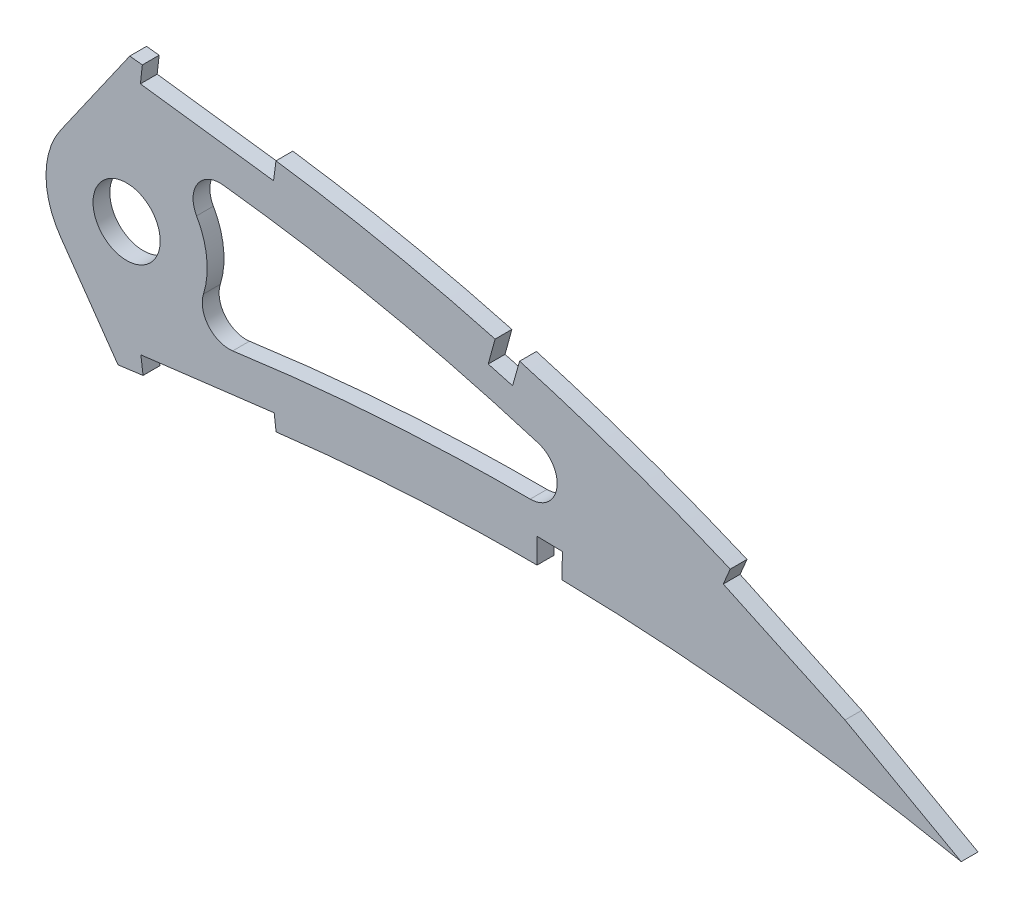
from build123d import *

# Parameters (mm, degrees)
BOSS_EXTRUDE1_DEPTH = 3.175
SKETCH3_R           = 6.35
CUT_EXTRUDE2_DEPTH  = 7.62
CUT_EXTRUDE3_DEPTH  = 4.1750001
CUT_EXTRUDE4_DEPTH  = 4.1750001
FILLET1_R           = 5.08


with BuildPart() as part:
    # Sketch1 → Boss-Extrude1 (new body)
    with BuildSketch(Plane.XY):
        with BuildLine():
            Line((468.834634376, -0.731838708), (473.237631437, -1.626460605))
            Line((473.237631437, -1.626460605), (469.420105342, 0.731838708))
            add(Edge.make_bspline(
                [(469.420105342, 0.731838708), (469.384144743, 0.75405358), (469.240441949, 0.842826831), (468.916653521, 1.041434293), (468.377478456, 1.372225024), (467.622680377, 1.832901279), (466.652845475, 2.422239826), (465.467485908, 3.136113979), (464.067341521, 3.972204372), (462.452751187, 4.926556606), (460.623880493, 5.99470234), (458.581425768, 7.172314172), (456.325564704, 8.452725095), (453.857171213, 9.830703338), (451.177092175, 11.299695359), (448.285834578, 12.853066351), (445.184433662, 14.482914856), (441.87408004, 16.182230896), (438.355377166, 17.941630348), (434.629984045, 19.753790881), (430.699141968, 21.609677497), (426.564192467, 23.499388025), (422.22751115, 25.41521975), (417.69029685, 27.345261464), (412.955135305, 29.281151436), (408.024042449, 31.211871947), (402.899937976, 33.12863011), (397.58479872, 35.019008566), (392.082597846, 36.874746386), (386.396004495, 38.68378787), (380.529085336, 40.436308543), (374.485249168, 42.120945686), (368.269534158, 43.72905958), (361.885882446, 45.248939331), (355.339704572, 46.670411418), (348.63620397, 47.984917711), (341.781002635, 49.179334611), (334.793097003, 50.252730987), (327.784920922, 51.145614984), (320.79116359, 52.021329621), (313.807821665, 52.843983365), (306.739128647, 53.631788144), (299.591885106, 54.380308437), (292.373180531, 55.087203561), (285.090322746, 55.749422771), (277.750880063, 56.365023912), (270.361954303, 56.930518839), (262.931336863, 57.445036287), (255.466373755, 57.904053071), (247.975016147, 58.307224442), (240.464868712, 58.651738691), (232.943747029, 58.935221873), (225.419637453, 59.155962801), (217.900350262, 59.311846649), (210.394026923, 59.401893322), (202.908475182, 59.423642443), (195.451832721, 59.376704816), (188.031907868, 59.259468925), (180.656846602, 59.07032975), (173.334467891, 58.808934388), (166.072689758, 58.475396129), (158.879463115, 58.066921878), (151.76259133, 57.586114694), (144.729999608, 57.030954849), (137.789414782, 56.401294687), (130.948110641, 55.699758895), (124.213703919, 54.924439317), (117.593411838, 54.077542083), (111.094475675, 53.160727588), (104.72418742, 52.173496373), (98.489371058, 51.118700137), (92.396755747, 49.997417995), (86.452787451, 48.81293722), (80.663937566, 47.565566874), (75.036333929, 46.259048591), (69.57582504, 44.895658843), (64.288280855, 43.477893405), (59.179061403, 42.009154361), (54.253333229, 40.492773824), (49.516838534, 38.930418047), (44.973157087, 37.328010693), (40.627870346, 35.686689303), (36.484306892, 34.011510412), (32.547322707, 32.304761192), (28.819858841, 30.571644792), (25.306133953, 28.814134252), (22.008652271, 27.037153572), (18.930724245, 25.243427453), (16.07531265, 23.436287722), (13.44361768, 21.620318123), (11.039267644, 19.796658613), (8.863088517, 17.969917436), (6.916457434, 16.142876281), (5.20215694, 14.316793669), (3.720125296, 12.494885385), (2.472304781, 10.678594294), (1.458911867, 8.869639065), (0.682238714, 7.069333725), (0.141515122, 5.278690749), (-0.154473369, 3.500353053), (-0.228146672, 1.732894981), (-0.07593526, 0.576768576), (0, 0)],
                knots=[0, 0, 0, 0, 0.00025409, 0.001015373, 0.002283359, 0.004056577, 0.006330982, 0.009105274, 0.012374489, 0.016134023, 0.020379661, 0.025105976, 0.030306237, 0.035972206, 0.042099522, 0.048678064, 0.055701664, 0.063160184, 0.071045824, 0.079349827, 0.08806291, 0.097175757, 0.106678111, 0.116561573, 0.126814276, 0.137428301, 0.148393618, 0.15969976, 0.171338125, 0.183297699, 0.195569604, 0.208143556, 0.221011593, 0.234161831, 0.24758745, 0.261276822, 0.27522271, 0.289414144, 0.3037712, 0.317689226, 0.331784111, 0.346039677, 0.36044387, 0.374982721, 0.389640454, 0.404403317, 0.4192566, 0.434186749, 0.449177265, 0.464214782, 0.479284009, 0.49436974, 0.509457833, 0.524532346, 0.53957932, 0.554582984, 0.569529546, 0.584403417, 0.599190992, 0.613876838, 0.628447475, 0.642888675, 0.657186054, 0.671325546, 0.685294014, 0.699078147, 0.712665095, 0.726042645, 0.739197713, 0.752117586, 0.764792042, 0.777208152, 0.789355685, 0.80122396, 0.812803686, 0.824082909, 0.835054602, 0.845709571, 0.856037853, 0.866033834, 0.875688843, 0.884997719, 0.893953426, 0.902552897, 0.910789386, 0.918660734, 0.926166253, 0.933302626, 0.94007122, 0.94647478, 0.952517526, 0.958204819, 0.963546652, 0.9685566, 0.973249913, 0.977651041, 0.981787043, 0.985694226, 0.989415109, 0.993001157, 0.996508416, 1, 1, 1, 1], degree=3))
            add(Edge.make_bspline(
                [(0, 0), (0.120545422, -0.569054782), (0.362190271, -1.709779619), (1.018707782, -3.35195076), (1.886920844, -4.930552911), (2.985051288, -6.441392915), (4.305797565, -7.884057869), (5.846242644, -9.260048331), (7.604875869, -10.568624397), (9.57939547, -11.809190578), (11.766933151, -12.983063792), (14.165030149, -14.089514173), (16.771499867, -15.128195969), (19.583502489, -16.097720727), (22.597600275, -16.999564994), (25.810927556, -17.83153108), (29.219830482, -18.594781746), (32.82103031, -19.287368785), (36.610602861, -19.909995783), (40.584611298, -20.462314276), (44.738976581, -20.94466978), (49.069622971, -21.356050059), (53.572267018, -21.697340041), (58.242420882, -21.968766107), (63.07555133, -22.171188915), (68.067028727, -22.30383895), (73.21196449, -22.368784292), (78.505709034, -22.366999873), (83.943083827, -22.298008468), (89.519444052, -22.165621357), (95.229438588, -21.969000009), (101.06791245, -21.710523747), (107.029599259, -21.392793842), (113.109152024, -21.016887343), (119.301220533, -20.584470276), (125.600428387, -20.099010447), (132.001053313, -19.561718629), (138.497513135, -18.97572672), (145.084056477, -18.343968166), (151.754992696, -17.668442476), (158.504433487, -16.952327301), (165.326367256, -16.197943271), (172.214990615, -15.40931492), (179.164010856, -14.587869186), (186.167551809, -13.738296088), (193.219024932, -12.862218898), (200.312533746, -11.963011893), (207.44169833, -11.044909074), (214.599844565, -10.107805674), (221.780951957, -9.158378258), (228.978095261, -8.195844739), (236.185009877, -7.225155571), (243.39502444, -6.249327898), (250.601116302, -5.268662037), (257.796951099, -4.287222096), (264.975853334, -3.307702419), (272.13079123, -2.33019238), (279.255291474, -1.35955068), (286.342179994, -0.395658656), (293.38492181, 0.559529456), (300.37676799, 1.503162571), (307.311122172, 2.434049592), (314.180831105, 3.351601668), (320.978983246, 4.256163344), (327.596964914, 5.120278953), (334.01748331, 5.989962795), (340.262174398, 6.702910859), (346.429111082, 7.311437642), (352.524699362, 7.810345682), (358.541619746, 8.206812681), (364.472978221, 8.503671562), (370.311705825, 8.705066897), (376.050427401, 8.816973355), (381.681975143, 8.842230751), (387.198662126, 8.788893941), (392.593313409, 8.66126226), (397.85839984, 8.46506453), (402.98657623, 8.20692007), (407.970558399, 7.89386613), (412.802863889, 7.530520429), (417.476759125, 7.125365523), (421.985033014, 6.684332445), (426.320762922, 6.212460013), (430.477622429, 5.719635759), (434.44895803, 5.209104646), (438.228796305, 4.68925635), (441.811052689, 4.165359017), (445.190053843, 3.644101417), (448.360490845, 3.130455994), (451.317242447, 2.631240452), (454.055677032, 2.151118888), (456.571042556, 1.694780117), (458.859849552, 1.267981745), (460.917577703, 0.872844052), (462.741474942, 0.515878932), (464.328149845, 0.198661447), (465.675276413, -0.074339095), (466.780502068, -0.302045374), (467.642148233, -0.480719316), (468.258513042, -0.610646491), (468.628929808, -0.68795975), (468.793510743, -0.723066602), (468.834634376, -0.731838708)],
                knots=[0, 0, 0, 0, 0.003638255, 0.007293231, 0.011028136, 0.014901081, 0.018963272, 0.023258475, 0.027820626, 0.032679082, 0.03785316, 0.043361875, 0.049214679, 0.055422346, 0.061988786, 0.068918036, 0.076211157, 0.083868392, 0.091887411, 0.100265912, 0.108999867, 0.118084529, 0.127514843, 0.13728527, 0.147387917, 0.157816481, 0.168563473, 0.179619128, 0.190977373, 0.202626974, 0.214560478, 0.226767249, 0.239236417, 0.251959004, 0.264923894, 0.278119703, 0.291536035, 0.30516028, 0.318980685, 0.332985499, 0.34716279, 0.361498603, 0.375980747, 0.390597192, 0.405332593, 0.420174823, 0.435109533, 0.450124276, 0.465203068, 0.480333154, 0.495500583, 0.510689775, 0.525887334, 0.541078314, 0.556247233, 0.571381785, 0.58646604, 0.601484516, 0.616424329, 0.631269423, 0.646006524, 0.660620684, 0.675098188, 0.689422858, 0.703581824, 0.716907564, 0.730009274, 0.742952128, 0.755725558, 0.768319952, 0.780724337, 0.792926528, 0.804916041, 0.816679084, 0.828203524, 0.8394749, 0.850481359, 0.861207697, 0.871639326, 0.881763414, 0.891563605, 0.901027364, 0.910138977, 0.918883976, 0.927249278, 0.935221104, 0.942784738, 0.949928188, 0.956638464, 0.962904204, 0.968712288, 0.974054485, 0.978918432, 0.983297218, 0.987180246, 0.990560674, 0.993433357, 0.995790626, 0.997629587, 0.998945816, 0.999736592, 1, 1, 1, 1], degree=3))
        make_face()
    extrude(amount=BOSS_EXTRUDE1_DEPTH)

    # Sketch3 → Cut-Extrude2 (cut)
    with BuildSketch(Plane(origin=(0, 0, 0), x_dir=(-1, 0, 0), z_dir=(0, 0, -1))):
        with Locations((-305.693087566, 26.255421435)):
            Circle(SKETCH3_R)
    extrude(amount=-CUT_EXTRUDE2_DEPTH, mode=Mode.SUBTRACT)

    # Sketch5 → Cut-Extrude3 (cut, through all)
    with BuildSketch(Plane.XY.offset(3.175)):
        with BuildLine():
            Line((297.512883475, 11.367834437), (293.209210411, 17.514116545))
            ThreePointArc((293.209210411, 17.514116545), (290.453087566, 26.255421435), (293.209210411, 34.996726325))
            Line((293.209210411, 34.996726325), (299.622888229, 44.156407516))
            Line((299.622888229, 44.156407516), (306.28625024, 53.672674691))
            add(Edge.make_bspline(
                [(306.28625024, 53.672674691), (304.062685855, 53.912052152), (299.432854271, 54.395881608), (292.373180531, 55.087203561), (285.090322746, 55.749422771), (277.750880063, 56.365023912), (270.361954303, 56.930518839), (262.931336863, 57.445036287), (255.466373755, 57.904053071), (247.975016147, 58.307224442), (240.464868712, 58.651738691), (232.943747029, 58.935221873), (225.419637453, 59.155962801), (217.900350262, 59.311846649), (210.394026923, 59.401893322), (202.908475182, 59.423642443), (195.451832721, 59.376704816), (188.031907868, 59.259468925), (180.656846602, 59.07032975), (173.334467891, 58.808934388), (166.072689758, 58.475396129), (159.219577295, 58.086235587), (154.78924534, 57.790330672), (152.756670288, 57.644702109)],
                knots=[0.347000218, 0.347000218, 0.347000218, 0.347000218, 0.36044387, 0.374982721, 0.389640454, 0.404403317, 0.4192566, 0.434186749, 0.449177265, 0.464214782, 0.479284009, 0.49436974, 0.509457833, 0.524532346, 0.53957932, 0.554582984, 0.569529546, 0.584403417, 0.599190992, 0.613876838, 0.628447475, 0.642888675, 0.655138283, 0.655138283, 0.655138283, 0.655138283], degree=3))
            add(Edge.make_bspline(
                [(152.756670288, 57.644702109), (152.416884114, 57.620357339), (149.731090186, 57.425745956), (144.729999608, 57.030954849), (137.789414782, 56.401294687), (130.948110641, 55.699758895), (124.213703919, 54.924439317), (117.593411838, 54.077542083), (111.094475675, 53.160727588), (104.72418742, 52.173496373), (98.489371058, 51.118700137), (92.396755747, 49.997417995), (86.452787451, 48.81293722), (80.663937566, 47.565566874), (75.036333929, 46.259048591), (69.57582504, 44.895658843), (64.288280855, 43.477893405), (59.179061403, 42.009154361), (54.253333229, 40.492773824), (49.516838534, 38.930418047), (44.973157087, 37.328010693), (40.627870346, 35.686689303), (36.484306892, 34.011510412), (32.547322707, 32.304761192), (28.819858841, 30.571644792), (25.306133953, 28.814134252), (22.008652271, 27.037153572), (18.930724245, 25.243427453), (16.07531265, 23.436287722), (13.44361768, 21.620318123), (11.039267644, 19.796658613), (8.863088517, 17.969917436), (6.916457434, 16.142876281), (5.20215694, 14.316793669), (3.720125296, 12.494885385), (2.472304781, 10.678594294), (1.458911867, 8.869639065), (0.682238714, 7.069333725), (0.141515122, 5.278690749), (-0.154473369, 3.500353053), (-0.228146672, 1.732894981), (-0.07593526, 0.576768576), (0, 0)],
                knots=[0.655138283, 0.655138283, 0.655138283, 0.655138283, 0.657186054, 0.671325546, 0.685294014, 0.699078147, 0.712665095, 0.726042645, 0.739197713, 0.752117586, 0.764792042, 0.777208152, 0.789355685, 0.80122396, 0.812803686, 0.824082909, 0.835054602, 0.845709571, 0.856037853, 0.866033834, 0.875688843, 0.884997719, 0.893953426, 0.902552897, 0.910789386, 0.918660734, 0.926166253, 0.933302626, 0.94007122, 0.94647478, 0.952517526, 0.958204819, 0.963546652, 0.9685566, 0.973249913, 0.977651041, 0.981787043, 0.985694226, 0.989415109, 0.993001157, 0.996508416, 1, 1, 1, 1], degree=3))
            add(Edge.make_bspline(
                [(0, 0), (0.120545422, -0.569054782), (0.362190271, -1.709779619), (1.018707782, -3.35195076), (1.886920844, -4.930552911), (2.985051288, -6.441392915), (4.305797565, -7.884057869), (5.846242644, -9.260048331), (7.604875869, -10.568624397), (9.57939547, -11.809190578), (11.766933151, -12.983063792), (14.165030149, -14.089514173), (16.771499867, -15.128195969), (19.583502489, -16.097720727), (22.597600275, -16.999564994), (25.810927556, -17.83153108), (29.219830482, -18.594781746), (32.82103031, -19.287368785), (36.610602861, -19.909995783), (40.584611298, -20.462314276), (44.738976581, -20.94466978), (49.069622971, -21.356050059), (53.572267018, -21.697340041), (58.242420882, -21.968766107), (63.07555133, -22.171188915), (68.067028727, -22.30383895), (73.21196449, -22.368784292), (78.505709034, -22.366999873), (83.943083827, -22.298008468), (89.519444052, -22.165621357), (95.229438588, -21.969000009), (101.06791245, -21.710523747), (107.029599259, -21.392793842), (113.109152024, -21.016887343), (119.301220533, -20.584470276), (125.600428387, -20.099010447), (132.001053313, -19.561718629), (138.497513135, -18.97572672), (145.084056477, -18.343968166), (151.754992696, -17.668442476), (158.504433487, -16.952327301), (165.326367256, -16.197943271), (172.214990615, -15.40931492), (178.413668021, -14.676567434), (182.315287371, -14.20522514), (183.900274287, -14.012143441)],
                knots=[0, 0, 0, 0, 0.003638255, 0.007293231, 0.011028136, 0.014901081, 0.018963272, 0.023258475, 0.027820626, 0.032679082, 0.03785316, 0.043361875, 0.049214679, 0.055422346, 0.061988786, 0.068918036, 0.076211157, 0.083868392, 0.091887411, 0.100265912, 0.108999867, 0.118084529, 0.127514843, 0.13728527, 0.147387917, 0.157816481, 0.168563473, 0.179619128, 0.190977373, 0.202626974, 0.214560478, 0.226767249, 0.239236417, 0.251959004, 0.264923894, 0.278119703, 0.291536035, 0.30516028, 0.318980685, 0.332985499, 0.34716279, 0.361498603, 0.375980747, 0.390597192, 0.400599477, 0.400599477, 0.400599477, 0.400599477], degree=3))
            Line((183.900274287, -14.012143441), (182.671674675, -3.926701309))
            add(Edge.make_bspline(
                [(182.671674675, -3.926701309), (194.509091827, -2.484677654), (218.145124651, 0.570902493), (247.751689591, 4.59382325), (271.453325847, 7.832408284), (286.063540768, 9.821970798), (294.75504791, 10.996225318), (297.512883475, 11.367834437)],
                knots=[0.400599477, 0.400599477, 0.400599477, 0.400599477, 0.475524542, 0.550449608, 0.587912141, 0.625374673, 0.642787324, 0.642787324, 0.642787324, 0.642787324], degree=3))
        make_face()
        with BuildLine():
            Line((304.072913741, 1.999140288), (297.512883475, 11.367834437))
            add(Edge.make_bspline(
                [(182.671674675, -3.926701309), (194.509091827, -2.484677654), (218.145124651, 0.570902493), (247.751689591, 4.59382325), (271.453325847, 7.832408284), (286.063540768, 9.821970798), (294.75504791, 10.996225318), (297.512883475, 11.367834437)],
                knots=[0.400599477, 0.400599477, 0.400599477, 0.400599477, 0.475524542, 0.550449608, 0.587912141, 0.625374673, 0.642787324, 0.642787324, 0.642787324, 0.642787324], degree=3))
            Line((182.671674675, -3.926701309), (183.900274287, -14.012143441))
            add(Edge.make_bspline(
                [(183.900274287, -14.012143441), (184.650295648, -13.920776504), (187.752075182, -13.541434417), (193.219024932, -12.862218898), (200.312533746, -11.963011893), (207.44169833, -11.044909074), (214.599844565, -10.107805674), (221.780951957, -9.158378258), (228.978095261, -8.195844739), (236.185009877, -7.225155571), (243.39502444, -6.249327898), (250.601116302, -5.268662037), (257.796951099, -4.287222096), (264.975853334, -3.307702419), (272.13079123, -2.33019238), (279.255291474, -1.35955068), (286.342179994, -0.395658656), (293.38492181, 0.559529456), (299.290252779, 1.356524372), (302.847355272, 1.834638254), (304.072913741, 1.999140288)],
                knots=[0.400599477, 0.400599477, 0.400599477, 0.400599477, 0.405332593, 0.420174823, 0.435109533, 0.450124276, 0.465203068, 0.480333154, 0.495500583, 0.510689775, 0.525887334, 0.541078314, 0.556247233, 0.571381785, 0.58646604, 0.601484516, 0.616424329, 0.631269423, 0.646006524, 0.653752682, 0.653752682, 0.653752682, 0.653752682], degree=3))
        make_face()
        with BuildLine():
            ThreePointArc((323.963245575, 41.38375935), (319.105220017, 39.160601573), (318.92248425, 33.821177403))
            ThreePointArc((318.92248425, 33.821177403), (320.421862217, 30.169600438), (320.933087566, 26.255421435))
            ThreePointArc((320.933087566, 26.255421435), (319.141171906, 19.085579904), (314.186810981, 13.601794976))
            add(Edge.make_bspline(
                [(314.186810981, 13.601794976), (314.770369848, 13.679448559), (316.839424195, 13.954520017), (320.400865114, 14.426308147), (324.846022745, 15.007024156), (329.250239262, 15.599262537), (333.841569886, 16.194898181), (338.429624656, 16.716888646), (347.573325078, 17.657008471), (361.374068863, 18.662672255), (379.786507532, 19.131635965), (397.590418024, 18.759722594), (409.224653606, 18.017132069), (414.729715702, 17.55731843)],
                knots=[0.677887055, 0.677887055, 0.677887055, 0.677887055, 0.681568472, 0.690934105, 0.700299739, 0.709665372, 0.719031005, 0.728396638, 0.737762271, 0.775224804, 0.812687337, 0.850149869, 0.883923306, 0.883923306, 0.883923306, 0.883923306], degree=3))
            add(Edge.make_bspline(
                [(414.729715702, 17.55731843), (413.495056563, 18.076609121), (406.144215059, 21.11795465), (392.493349368, 26.215886187), (373.537808804, 32.037686314), (357.474318794, 35.923573168), (346.138104248, 38.119647891), (339.615899628, 39.226410516), (334.729973243, 39.983396346), (329.989581028, 40.625614959), (326.342829232, 41.085317779), (324.383215707, 41.331189805), (323.963245575, 41.38375935)],
                knots=[0.114549081, 0.114549081, 0.114549081, 0.114549081, 0.122838428, 0.163784571, 0.204730714, 0.245676856, 0.266149928, 0.276386463, 0.286622999, 0.296859535, 0.306234702, 0.308793836, 0.308793836, 0.308793836, 0.308793836], degree=3))
        make_face()
    extrude(amount=-CUT_EXTRUDE3_DEPTH, mode=Mode.SUBTRACT)

    # Sketch6 → Cut-Extrude4 (cut, through all)
    with BuildSketch(Plane.XY.offset(3.175)):
        with BuildLine():
            add(Edge.make_bspline(
                [(333.929911323, 50.341851873), (331.859314578, 50.626471459), (327.488961608, 51.182673162), (320.79116359, 52.021329621), (314.442152858, 52.769257691), (310.390101293, 53.224342073), (308.667703913, 53.413625761)],
                knots=[0.291207141, 0.291207141, 0.291207141, 0.291207141, 0.3037712, 0.317689226, 0.331784111, 0.342200224, 0.342200224, 0.342200224, 0.342200224], degree=3))
            Line((333.929911323, 50.341851873), (334.512065277, 54.823626972))
            Line((334.512065277, 54.823626972), (309.146518106, 57.674243029))
            Line((309.146518106, 57.674243029), (308.667703913, 53.413625761))
        make_face()
        Polygon((308.652395584, 53.277408137), (308.297850756, 50.122573044), (333.476163247, 46.848623298), (333.885132121, 49.99711435), align=None)
        with BuildLine():
            Line((377.256283552, 48.81691022), (375.355182384, 41.865517827))
            add(Edge.make_bspline(
                [(379.995119199, 40.570141398), (378.451581941, 41.012961679), (376.904875173, 41.44473681), (375.355182384, 41.865517827)],
                knots=[0.196772604, 0.196772604, 0.196772604, 0.196772604, 0.206425369, 0.206425369, 0.206425369, 0.206425369], degree=3))
            Line((379.995119199, 40.570141398), (381.952411943, 47.532589804))
            Line((381.952411943, 47.532589804), (377.256283552, 48.81691022))
        make_face()
        Polygon((375.317230972, 41.726748172), (374.060981287, 37.133260641), (378.654468816, 35.877010948), (379.953838632, 40.423298869), align=None)
        with BuildLine():
            Line((422.639110826, 33.097771033), (419.814536432, 26.438469199))
            add(Edge.make_bspline(
                [(469.420105342, 0.731838708), (469.384144743, 0.75405358), (469.240441949, 0.842826831), (468.916653521, 1.041434293), (468.377478456, 1.372225024), (467.622680377, 1.832901279), (466.652845475, 2.422239826), (465.467485908, 3.136113979), (464.067341521, 3.972204372), (462.452751187, 4.926556606), (460.623880493, 5.99470234), (458.581425768, 7.172314172), (456.325564704, 8.452725095), (453.857171213, 9.830703338), (451.177092175, 11.299695359), (448.285834578, 12.853066351), (445.184433662, 14.482914856), (441.87408004, 16.182230896), (438.355377166, 17.941630348), (434.629984045, 19.753790881), (430.699141968, 21.609677497), (426.564192467, 23.499388025), (422.913014033, 25.112382609), (420.638113453, 26.088706889), (419.814536432, 26.438469199)],
                knots=[0, 0, 0, 0, 0.00025409, 0.001015373, 0.002283359, 0.004056577, 0.006330982, 0.009105274, 0.012374489, 0.016134023, 0.020379661, 0.025105976, 0.030306237, 0.035972206, 0.042099522, 0.048678064, 0.055701664, 0.063160184, 0.071045824, 0.079349827, 0.08806291, 0.097175757, 0.106678111, 0.112056765, 0.112056765, 0.112056765, 0.112056765], degree=3))
            Line((469.420105342, 0.731838708), (473.237631437, -1.626460605))
            Line((473.237631437, -1.626460605), (468.834634376, -0.731838708))
            add(Edge.make_bspline(
                [(463.749174115, 0.314183331), (463.968637418, 0.270270157), (464.637675863, 0.135934772), (465.675276413, -0.074339095), (466.780502068, -0.302045374), (467.642148233, -0.480719316), (468.258513042, -0.610646491), (468.628929808, -0.68795975), (468.793510743, -0.723066602), (468.834634376, -0.731838708)],
                knots=[0.989158632, 0.989158632, 0.989158632, 0.989158632, 0.990560674, 0.993433357, 0.995790626, 0.997629587, 0.998945816, 0.999736592, 1, 1, 1, 1], degree=3))
            Line((463.749174115, 0.314183331), (463.708217496, 0.240451635))
            Line((463.708217496, 0.240451635), (477.098083011, -7.197375657))
            Line((477.098083011, -7.197375657), (481.361821085, 0.478371192))
            Line((481.361821085, 0.478371192), (422.639110826, 33.097771033))
        make_face()
        with BuildLine():
            add(Edge.make_bspline(
                [(383.284143211, 8.821702739), (384.602443262, 8.812950046), (386.170805311, 8.794643543), (387.739009395, 8.766883068), (387.989086643, 8.762215879)],
                knots=[0.819945141, 0.819945141, 0.819945141, 0.819945141, 0.828203524, 0.829770352, 0.829770352, 0.829770352, 0.829770352], degree=3))
            Line((387.989086643, 8.762215879), (388.085526515, 13.444014284))
            Line((388.085526515, 13.444014284), (383.32453269, 13.542120476))
            Line((383.32453269, 13.542120476), (383.28414321, 8.821702739))
        make_face()
        Polygon((383.231357966, 2.65256153), (387.863234516, 2.65256153), (387.98804622, 8.711707232), (383.283788284, 8.780221608), align=None)
        with BuildLine():
            Line((308.38825603, 5.800209772), (308.801977154, 2.652337229))
            Line((308.801977154, 2.652337229), (310.701505473, 2.886714965))
            add(Edge.make_bspline(
                [(310.701505473, 2.886714965), (311.869345474, 3.042728563), (315.303820941, 3.501026622), (320.978983246, 4.256163344), (327.564082502, 5.115985468), (331.879148983, 5.700318423), (333.95703077, 5.960133358)],
                knots=[0.667717454, 0.667717454, 0.667717454, 0.667717454, 0.675098188, 0.689422858, 0.703581824, 0.716699828, 0.716699828, 0.716699828, 0.716699828], degree=3))
            Line((333.95703077, 5.960133358), (333.591696942, 8.909442836))
            Line((333.591696942, 8.909442836), (308.38825603, 5.800209772))
        make_face()
        with BuildLine():
            add(Edge.make_bspline(
                [(308.804349352, 2.633111611), (309.436727547, 2.717699531), (310.069113071, 2.802232662), (310.701505473, 2.886714965)],
                knots=[0.663720743, 0.663720743, 0.663720743, 0.663720743, 0.667717454, 0.667717454, 0.667717454, 0.667717454], degree=3))
            Line((308.804349352, 2.633111611), (309.311930258, -1.480608059))
            Line((309.311930258, -1.480608059), (334.491870837, 1.626277701))
            Line((334.491870837, 1.626277701), (333.981917733, 5.759222988))
            Line((333.981917733, 5.759222988), (310.701505473, 2.886714965))
        make_face()
        with BuildLine():
            Line((308.652395584, 53.277408137), (333.885132121, 49.99711435))
            Line((333.885132121, 49.99711435), (333.929911323, 50.341851873))
            add(Edge.make_bspline(
                [(333.929911323, 50.341851873), (331.859314578, 50.626471459), (327.488961608, 51.182673162), (320.79116359, 52.021329621), (314.442152858, 52.769257691), (310.390101293, 53.224342073), (308.667703913, 53.413625761)],
                knots=[0.291207141, 0.291207141, 0.291207141, 0.291207141, 0.3037712, 0.317689226, 0.331784111, 0.342200224, 0.342200224, 0.342200224, 0.342200224], degree=3))
            Line((308.667703913, 53.413625761), (308.652395584, 53.277408137))
        make_face()
        with BuildLine():
            add(Edge.make_bspline(
                [(379.995119199, 40.570141398), (378.451581941, 41.012961679), (376.904875173, 41.44473681), (375.355182384, 41.865517827)],
                knots=[0.196772604, 0.196772604, 0.196772604, 0.196772604, 0.206425369, 0.206425369, 0.206425369, 0.206425369], degree=3))
            Line((375.355182384, 41.865517827), (375.317230972, 41.726748172))
            Line((375.317230972, 41.726748172), (379.953838632, 40.423298869))
            Line((379.953838632, 40.423298869), (379.995119199, 40.570141398))
        make_face()
        with BuildLine():
            add(Edge.make_bspline(
                [(469.420105342, 0.731838708), (469.384144743, 0.75405358), (469.240441949, 0.842826831), (468.916653521, 1.041434293), (468.377478456, 1.372225024), (467.622680377, 1.832901279), (466.652845475, 2.422239826), (465.467485908, 3.136113979), (464.067341521, 3.972204372), (462.452751187, 4.926556606), (460.623880493, 5.99470234), (458.581425768, 7.172314172), (456.325564704, 8.452725095), (453.857171213, 9.830703338), (451.177092175, 11.299695359), (448.285834578, 12.853066351), (445.184433662, 14.482914856), (441.87408004, 16.182230896), (438.355377166, 17.941630348), (434.629984045, 19.753790881), (430.699141968, 21.609677497), (426.564192467, 23.499388025), (422.913014033, 25.112382609), (420.638113453, 26.088706889), (419.814536432, 26.438469199)],
                knots=[0, 0, 0, 0, 0.00025409, 0.001015373, 0.002283359, 0.004056577, 0.006330982, 0.009105274, 0.012374489, 0.016134023, 0.020379661, 0.025105976, 0.030306237, 0.035972206, 0.042099522, 0.048678064, 0.055701664, 0.063160184, 0.071045824, 0.079349827, 0.08806291, 0.097175757, 0.106678111, 0.112056765, 0.112056765, 0.112056765, 0.112056765], degree=3))
            Line((419.814536432, 26.438469199), (419.733830693, 26.248194912))
            Line((419.733830693, 26.248194912), (418.494223412, 23.325659377))
            Line((418.494223412, 23.325659377), (441.504279945, 12.574335985))
            Line((441.504279945, 12.574335985), (463.477912059, 0.368382126))
            add(Edge.make_bspline(
                [(463.477912059, 0.368382126), (463.568337872, 0.350341588), (463.65875848, 0.33227491), (463.749174115, 0.314183331)],
                knots=[0.988581011, 0.988581011, 0.988581011, 0.988581011, 0.989158632, 0.989158632, 0.989158632, 0.989158632], degree=3))
            add(Edge.make_bspline(
                [(463.749174115, 0.314183331), (463.968637418, 0.270270157), (464.637675863, 0.135934772), (465.675276413, -0.074339095), (466.780502068, -0.302045374), (467.642148233, -0.480719316), (468.258513042, -0.610646491), (468.628929808, -0.68795975), (468.793510743, -0.723066602), (468.834634376, -0.731838708)],
                knots=[0.989158632, 0.989158632, 0.989158632, 0.989158632, 0.990560674, 0.993433357, 0.995790626, 0.997629587, 0.998945816, 0.999736592, 1, 1, 1, 1], degree=3))
            Line((468.834634376, -0.731838708), (473.237631437, -1.626460605))
            Line((473.237631437, -1.626460605), (469.420105342, 0.731838708))
        make_face()
        with BuildLine():
            add(Edge.make_bspline(
                [(310.701505473, 2.886714965), (311.869345474, 3.042728563), (315.303820941, 3.501026622), (320.978983246, 4.256163344), (327.564082502, 5.115985468), (331.879148983, 5.700318423), (333.95703077, 5.960133358)],
                knots=[0.667717454, 0.667717454, 0.667717454, 0.667717454, 0.675098188, 0.689422858, 0.703581824, 0.716699828, 0.716699828, 0.716699828, 0.716699828], degree=3))
            Line((310.701505473, 2.886714965), (333.981917733, 5.759222988))
            Line((333.981917733, 5.759222988), (333.95703077, 5.960133358))
        make_face()
        with BuildLine():
            Line((308.801977154, 2.652337229), (308.804349352, 2.633111611))
            add(Edge.make_bspline(
                [(308.804349352, 2.633111611), (309.436727547, 2.717699531), (310.069113071, 2.802232662), (310.701505473, 2.886714965)],
                knots=[0.663720743, 0.663720743, 0.663720743, 0.663720743, 0.667717454, 0.667717454, 0.667717454, 0.667717454], degree=3))
            Line((310.701505473, 2.886714965), (308.801977154, 2.652337229))
        make_face()
    extrude(amount=-CUT_EXTRUDE4_DEPTH, mode=Mode.SUBTRACT)

    # Fillet1
    fillet1_edges = [part.edges().sort_by_distance(p)[0] for p in [
        (414.729715702, 17.55731843, 1.5875),
        (314.186810981, 13.601794976, 1.5875),
    ]]
    fillet(fillet1_edges, radius=FILLET1_R)


solid = part.part
